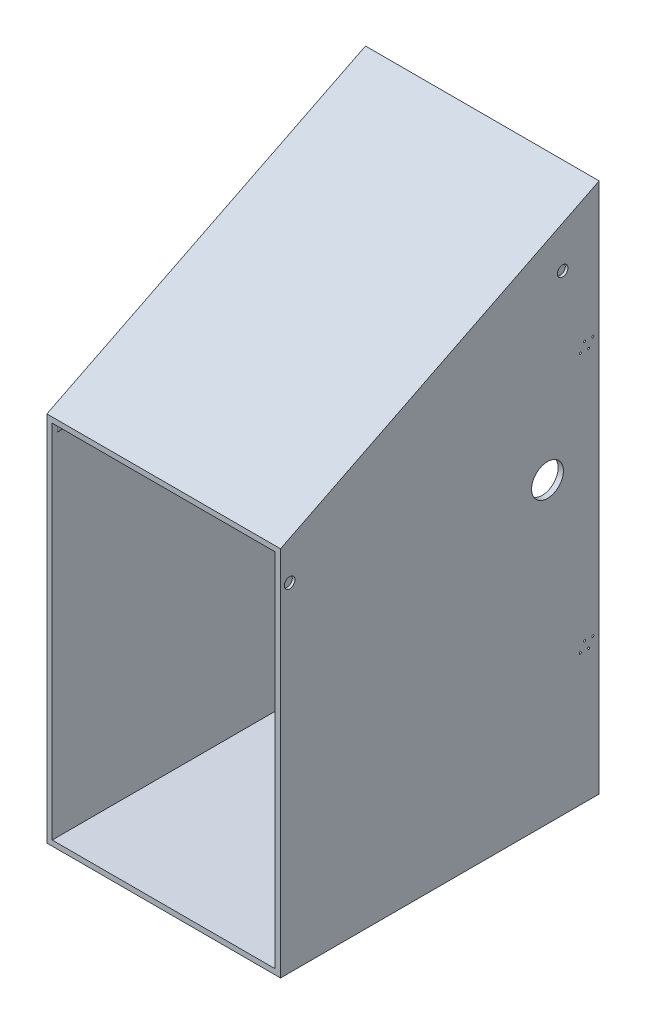
from build123d import *

# Parameters (mm, degrees)
SKETCH1_W           = 558.8
SKETCH1_H           = 889
BOSS_EXTRUDE1_DEPTH = 762
BOSS_EXTRUDE2_DEPTH = 558.8
SKETCH4_W           = 533.4
SKETCH4_H           = 127
CUT_EXTRUDE1_DEPTH  = 763
SKETCH5_W           = 533.4
SKETCH5_H           = 723.9
CUT_EXTRUDE3_DEPTH  = 755.142
SKETCH6_W           = 533.4
SKETCH6_H           = 889
CUT_EXTRUDE4_DEPTH  = 10.16
SKETCH7_R           = 38.1
CUT_EXTRUDE5_DEPTH  = 559.8
CUT_EXTRUDE6_DEPTH  = 533.908
CUT_EXTRUDE7_REACH  = 764
SKETCH12_W          = 533.4
SKETCH12_H          = 12.7
SKETCH13_R          = 2.5
SKETCH13_R_2        = 12.7
BOSS_EXTRUDE3_DEPTH = 6.35
SKETCH14_R          = 12.7
SKETCH14_R_2        = 2.5
CUT_EXTRUDE8_DEPTH  = 6.35
SKETCH15_R          = 12.7
CUT_EXTRUDE9_DEPTH  = 6.35


with BuildPart() as part:
    # Sketch1 → Boss-Extrude1 (new body)
    with BuildSketch(Plane.XY):
        with Locations((279.4, 444.5)):
            Rectangle(SKETCH1_W, SKETCH1_H)
    extrude(amount=BOSS_EXTRUDE1_DEPTH)

    # Sketch3 → Boss-Extrude2 (add)
    with BuildSketch(Plane(origin=(558.8, 0, 0), x_dir=(0, 0, -1), z_dir=(1, 0, 0))):
        Polygon((0, 889), (0, 1270), (-762, 889), align=None)
    extrude(amount=-BOSS_EXTRUDE2_DEPTH)

    # Sketch4 → Cut-Extrude1 (cut, through all)
    with BuildSketch(Plane.XY.offset(762)):
        with Locations((279.4, 76.2)):
            Rectangle(SKETCH4_W, SKETCH4_H)
    extrude(amount=-CUT_EXTRUDE1_DEPTH, mode=Mode.SUBTRACT)

    # Sketch5 → Cut-Extrude3 (cut)
    with BuildSketch(Plane.XY.offset(762)):
        with Locations((279.4, 514.35)):
            Rectangle(SKETCH5_W, SKETCH5_H)
    extrude(amount=-CUT_EXTRUDE3_DEPTH, mode=Mode.SUBTRACT)

    # Sketch6 → Cut-Extrude4 (cut)
    with BuildSketch(Plane(origin=(0, 0, 0), x_dir=(-1, 0, 0), z_dir=(0, 0, -1))):
        with Locations((-279.4, 800.1)):
            Rectangle(SKETCH6_W, SKETCH6_H)
    extrude(amount=-CUT_EXTRUDE4_DEPTH, mode=Mode.SUBTRACT)

    # Sketch7 → Cut-Extrude5 (cut, through all)
    with BuildSketch(Plane.ZY):
        with Locations((123.444, 712.216)):
            Circle(SKETCH7_R)
    extrude(amount=-CUT_EXTRUDE5_DEPTH, mode=Mode.SUBTRACT)

    # Sketch11 → Cut-Extrude6 (cut)
    with BuildSketch(Plane.ZY.offset(-546.1)):
        Polygon((0, 880.877149752), (0, 1247.656728703), (749.847637181, 880.877149752), (749.847637181, 851.37553613), (0, 851.37553613), align=None)
    extrude(amount=CUT_EXTRUDE6_DEPTH, mode=Mode.SUBTRACT)

    # Sketch12 → Cut-Extrude7 (cut, up to next)
    with BuildSketch(Plane.XY.offset(762), mode=Mode.PRIVATE) as cut_extrude7_sk1:
        with Locations((279.4, 146.05)):
            Rectangle(SKETCH12_W, SKETCH12_H)
    cut_extrude7_tool1 = extrude(cut_extrude7_sk1.sketch, amount=-CUT_EXTRUDE7_REACH, mode=Mode.PRIVATE) & part.part
    add(cut_extrude7_tool1.solids().sort_by_distance((279.4, 146.05, 762))[0], mode=Mode.SUBTRACT)

    # Sketch13 → Boss-Extrude3 (add)
    with BuildSketch(Plane.ZY):
        with Locations((45, 955.20656175)):
            Circle(SKETCH13_R)
        with Locations((25, 955.20656175)):
            Circle(SKETCH13_R)
        with Locations((35, 935.20656175)):
            Circle(SKETCH13_R)
        with Locations((15, 935.20656175)):
            Circle(SKETCH13_R)
        with Locations((740.165987986, 807.854465699)):
            Circle(SKETCH13_R_2)
        with Locations((35, 314.79343825)):
            Circle(SKETCH13_R)
        with Locations((45, 334.79343825)):
            Circle(SKETCH13_R)
        with Locations((25, 334.79343825)):
            Circle(SKETCH13_R)
        with Locations((15, 314.79343825)):
            Circle(SKETCH13_R)
    extrude(amount=BOSS_EXTRUDE3_DEPTH)

    # Sketch14 → Cut-Extrude8 (cut)
    with BuildSketch(Plane(origin=(558.8, 0, 0), x_dir=(0, 0, -1), z_dir=(1, 0, 0))):
        with Locations((-87.309700123, 1127.19181172)):
            Circle(SKETCH14_R)
        with Locations((-740.165987986, 807.854465699)):
            Circle(SKETCH14_R)
        with Locations((-25, 935.20656175)):
            Circle(SKETCH14_R_2)
        with Locations((-45, 935.20656175)):
            Circle(SKETCH14_R_2)
        with Locations((-35, 955.20656175)):
            Circle(SKETCH14_R_2)
        with Locations((-15, 955.20656175)):
            Circle(SKETCH14_R_2)
        with Locations((-25, 314.79343825)):
            Circle(SKETCH14_R_2)
        with Locations((-45, 314.79343825)):
            Circle(SKETCH14_R_2)
        with Locations((-35, 334.79343825)):
            Circle(SKETCH14_R_2)
        with Locations((-15, 334.79343825)):
            Circle(SKETCH14_R_2)
    extrude(amount=-CUT_EXTRUDE8_DEPTH, mode=Mode.SUBTRACT)

    # Sketch15 → Cut-Extrude9 (cut)
    with BuildSketch(Plane.ZY):
        with Locations((87.309700123, 1127.19181172)):
            Circle(SKETCH15_R)
    extrude(amount=-CUT_EXTRUDE9_DEPTH, mode=Mode.SUBTRACT)


solid = part.part
